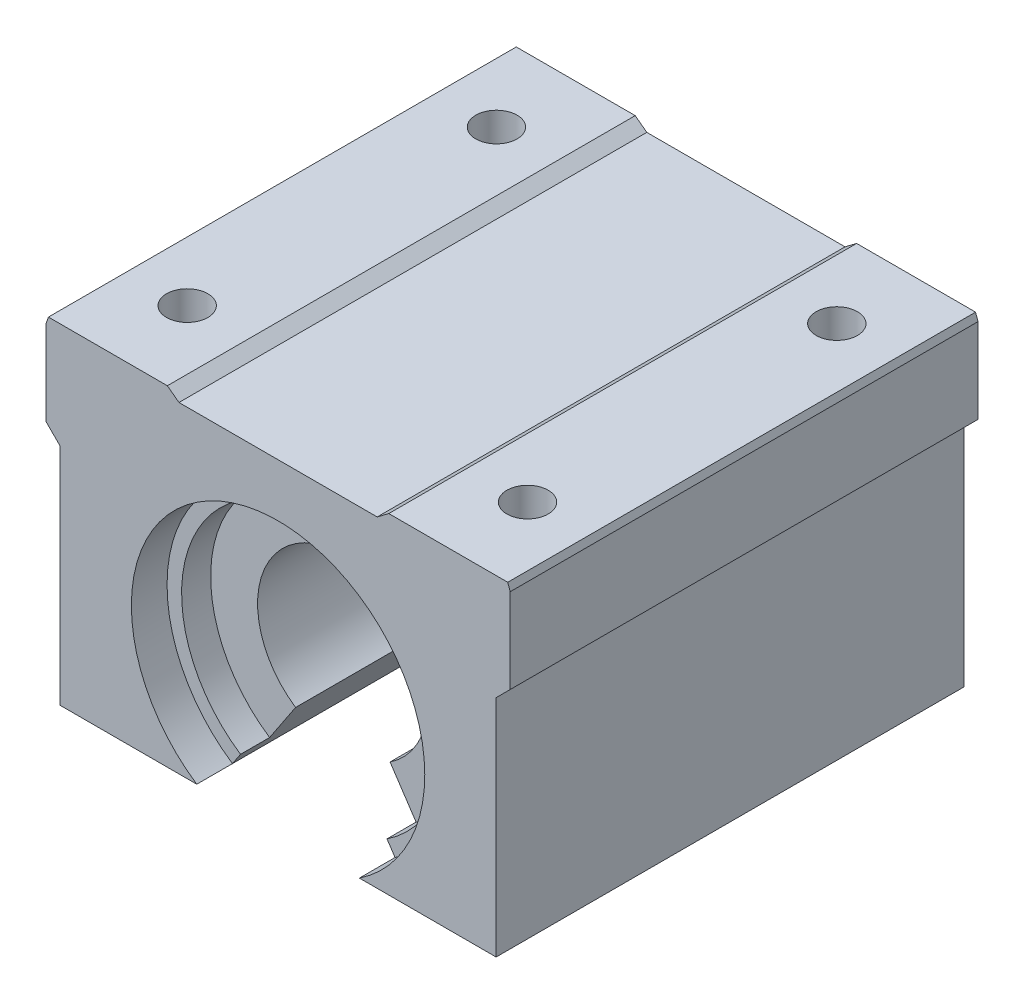
from build123d import *

# Parameters (mm, degrees)
BOSS_EXTRUDE1_DEPTH                 = 22.479
F_5_32_0_15625_DIAMETER_HOLE1_D     = 3.96875
F_5_32_0_15625_DIAMETER_HOLE1_DEPTH = 31.75
SKETCH17_R                          = 14.097
CUT_EXTRUDE1_DEPTH                  = 1
CUT_EXTRUDE1_DEPTH_BACK             = 45.958
BOSS_EXTRUDE2_DEPTH                 = 19.05
BOSS_EXTRUDE3_DEPTH                 = 16.256


with BuildPart() as part:
    # Sketch2 → Boss-Extrude1 (new body, symmetric)
    with BuildSketch(Plane.XY):
        Polygon((22.06839298, 16.2941), (10.63839298, 16.2941), (9.525, 15.4559), (-9.525, 15.4559), (-10.63839298, 16.2941), (-22.06839298, 16.2941), (-22.3012, 15.619179923), (-22.3012, 7.4803), (-20.955, 6.1341), (-20.955, -15.4559), (20.955, -15.4559), (20.955, 6.1341), (22.3012, 7.4803), (22.3012, 15.619179923), align=None)
    extrude(amount=BOSS_EXTRUDE1_DEPTH, both=True)

    # 5/32 (0.15625) Diameter Hole1
    with Locations(Plane(origin=(0, 16.2941, 0), x_dir=(1, 0, 0), z_dir=(0, 1, 0))):
        with Locations((-16.35339298, 14.859), (-16.35339298, -14.859), (16.35339298, -14.859), (16.35339298, 14.859)):
            Hole(F_5_32_0_15625_DIAMETER_HOLE1_D / 2, depth=F_5_32_0_15625_DIAMETER_HOLE1_DEPTH)

    # Sketch17 → Cut-Extrude1 (cut, two sides)
    with BuildSketch(Plane.XY.offset(22.479)) as cut_extrude1_sk:
        with Locations((0, -3.7211)):
            Circle(SKETCH17_R)
    extrude(amount=CUT_EXTRUDE1_DEPTH, mode=Mode.SUBTRACT)
    extrude(cut_extrude1_sk.sketch, amount=-CUT_EXTRUDE1_DEPTH_BACK, mode=Mode.SUBTRACT)

    # Sketch18 → Boss-Extrude2 (add, symmetric)
    with BuildSketch(Plane.XY):
        with BuildLine():
            Line((-7.811522128, -15.4559), (-7.037407323, -14.292991892))
            ThreePointArc((-7.037407323, -14.292991892), (0, 8.9789), (7.037407323, -14.292991892))
            Line((7.037407323, -14.292991892), (7.811522128, -15.4559))
            ThreePointArc((7.811522128, -15.4559), (0, 10.3759), (-7.811522128, -15.4559))
        make_face()
    extrude(amount=BOSS_EXTRUDE2_DEPTH, both=True)

    # Sketch19 → Boss-Extrude3 (add, symmetric)
    with BuildSketch(Plane.XY):
        with BuildLine():
            Line((-7.037407323, -14.292991892), (-4.539127723, -10.53997027))
            ThreePointArc((-4.539127723, -10.53997027), (0, 4.4704), (4.539127723, -10.53997027))
            Line((4.539127723, -10.53997027), (7.037407323, -14.292991892))
            ThreePointArc((7.037407323, -14.292991892), (0, 8.9789), (-7.037407323, -14.292991892))
        make_face()
    extrude(amount=BOSS_EXTRUDE3_DEPTH, both=True)


solid = part.part
